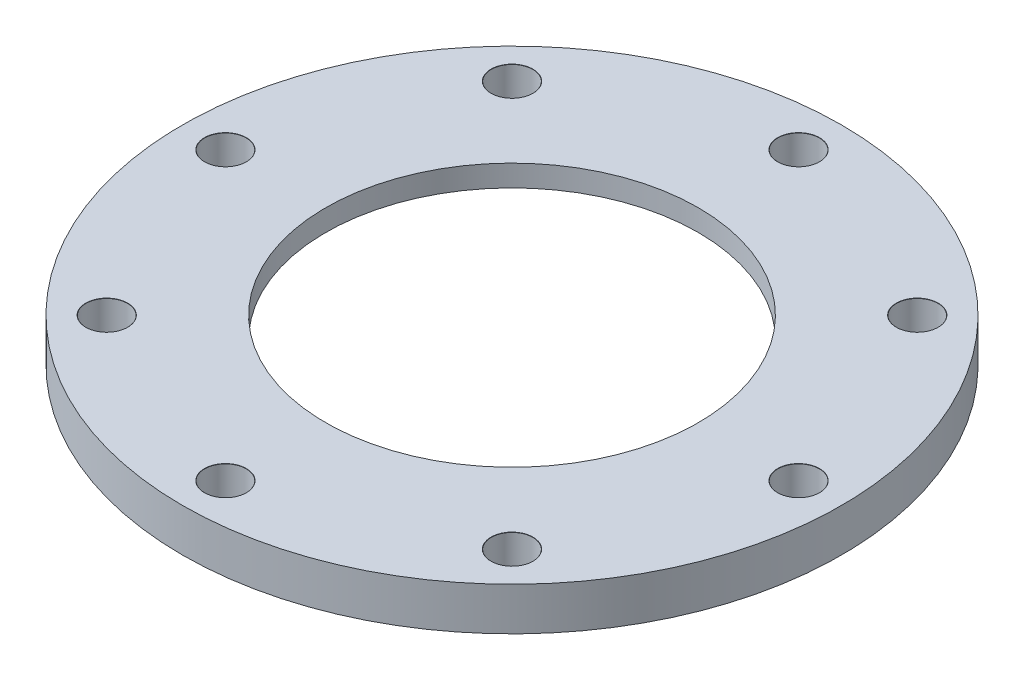
from build123d import *

# Parameters (mm, degrees)
M5_CLEARANCE_HOLE1_D           = 5.8
M5_CLEARANCE_HOLE1_DEPTH       = 6
M5_CLEARANCE_HOLE1_CSINK_D     = 5.85
M5_CLEARANCE_HOLE1_CSINK_ANGLE = 90
CIRPATTERN1_COUNT              = 8


with BuildPart() as part:
    # Sketch1 → Revolve1 (revolve)
    with BuildSketch(Plane.XY):
        Polygon((-32, 0), (-46, 0), (-46, 6), (-26, 6), (-26, 3), (-32, 3), align=None)
    revolve(axis=Axis((0, 0, 0), (0, 1, 0)))

    # M5 Clearance Hole1
    with Locations(Plane(origin=(0, 6, 0), x_dir=(1, 0, 0), z_dir=(0, 1, 0))):
        with Locations((40, 0)):
            m5_clearance_hole1 = CounterSinkHole(M5_CLEARANCE_HOLE1_D / 2, M5_CLEARANCE_HOLE1_CSINK_D / 2, depth=M5_CLEARANCE_HOLE1_DEPTH, counter_sink_angle=M5_CLEARANCE_HOLE1_CSINK_ANGLE)

    # CirPattern1: M5 Clearance Hole1 ×8 about axis
    cirpattern1_axis = Axis((0, 0, 0), (0, 1, 0))
    for i in range(1, CIRPATTERN1_COUNT):
        add(m5_clearance_hole1.rotate(cirpattern1_axis, i * 360 / CIRPATTERN1_COUNT), mode=Mode.SUBTRACT)


solid = part.part
